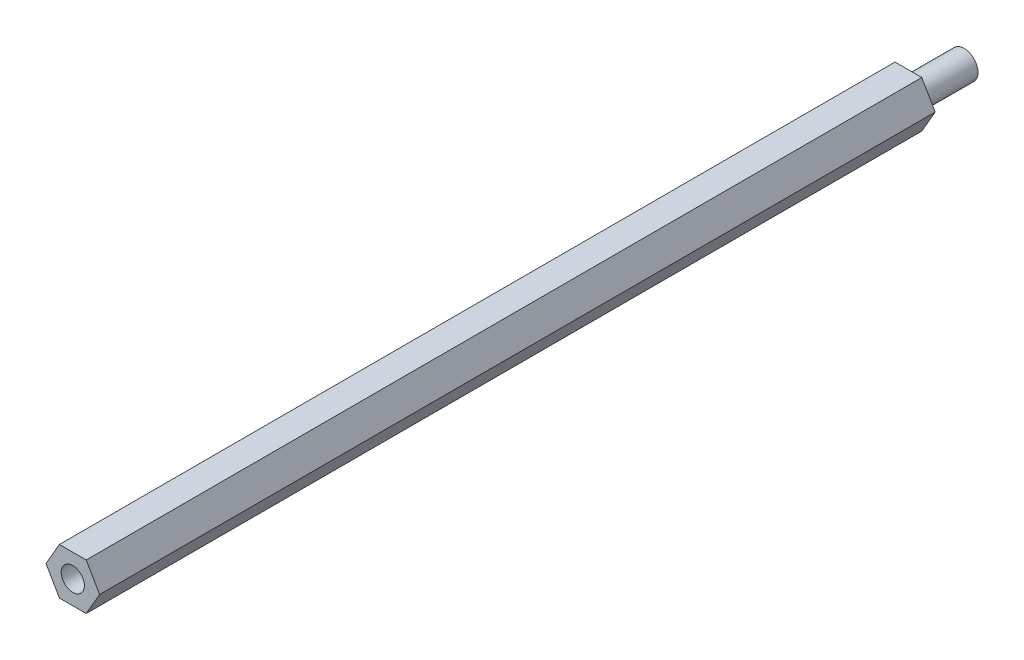
from build123d import *

# Parameters (mm, degrees)
EXTRUDE_1_DEPTH = 90
SKETCH_4_R      = 1.5
EXTRUDE_2_DEPTH = 6
M3X0_5_1_D      = 2.5
M3X0_5_1_DEPTH  = 7.5
M3X0_5_1_TIP    = 0.751075774


with BuildPart() as part:
    # 草圖1 → 填料-伸長1 (new body)
    with BuildSketch(Plane.XY):
        Polygon((-1.443375673, 2.5), (-2.886751346, 0), (-1.443375673, -2.5), (1.443375673, -2.5), (2.886751346, 0), (1.443375673, 2.5), align=None)
    extrude(amount=EXTRUDE_1_DEPTH)

    # 草圖4 → 填料-伸長2 (add)
    with BuildSketch(Plane(origin=(0, 0, 0), x_dir=(-1, 0, 0), z_dir=(0, 0, -1))):
        Circle(SKETCH_4_R)
    extrude(amount=EXTRUDE_2_DEPTH)

    # M3x0.5 螺紋孔1
    with Locations(Plane.XY.offset(90)):
        with Locations((0, 0)):
            Hole(M3X0_5_1_D / 2, depth=M3X0_5_1_DEPTH)
            with Locations((0, 0, -(M3X0_5_1_DEPTH + M3X0_5_1_TIP / 2))):  # 118° drill point
                Cone(0, M3X0_5_1_D / 2, M3X0_5_1_TIP, mode=Mode.SUBTRACT)


solid = part.part
